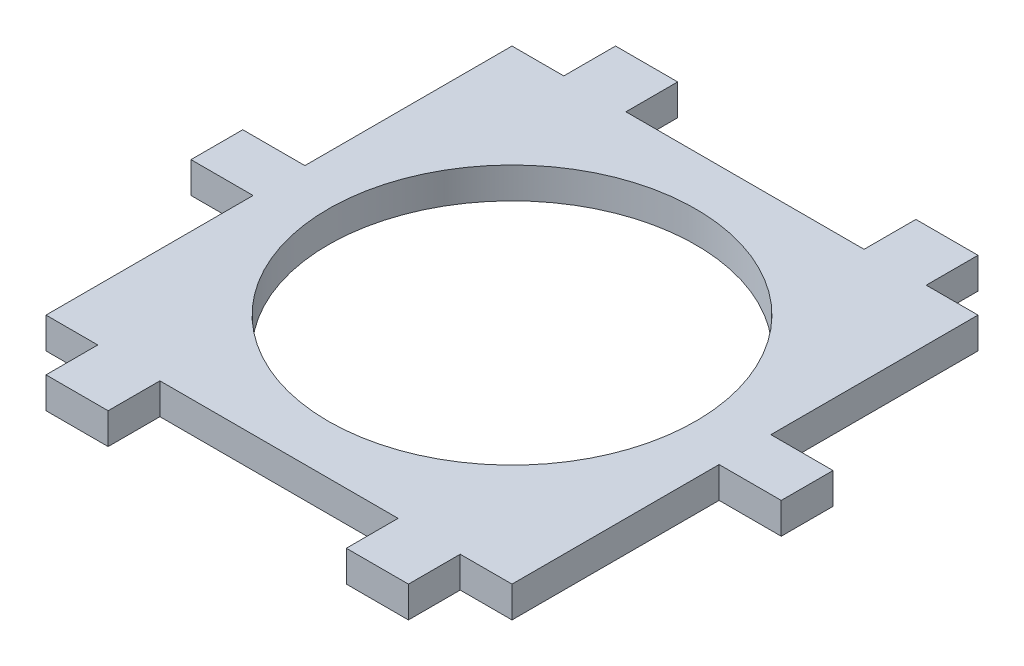
from build123d import *

# Parameters (mm, degrees)
CROQUIS1_R              = 17.75
SALIENTE_EXTRUIR1_DEPTH = 3
CROQUIS1_3_W            = 6
CROQUIS1_3_H            = 5
SALIENTE_EXTRUIR2_DEPTH = 3


with BuildPart() as part:
    # Croquis1 → Saliente-Extruir1 (new body)
    with BuildSketch(Plane(origin=(0, 0, 0), x_dir=(1, 0, 0), z_dir=(0, 1, 0))):
        Polygon((-17.5, 22.5), (-22.5, 22.5), (-22.5, -22.5), (-17.5, -22.5), (-17.5, -27.5), (-11.5, -27.5), (-11.5, -22.5), (11.5, -22.5), (11.5, -27.5), (17.5, -27.5), (17.5, -22.5), (22.5, -22.5), (22.5, 22.5), (17.5, 22.5), (17.5, 27.5), (11.5, 27.5), (11.5, 22.5), (-11.5, 22.5), (-11.5, 27.5), (-17.5, 27.5), align=None)
        Circle(CROQUIS1_R, mode=Mode.SUBTRACT)
    extrude(amount=SALIENTE_EXTRUIR1_DEPTH)

    # Croquis1_3 → Saliente-Extruir2 (add)
    with BuildSketch(Plane(origin=(0, 0, 0), x_dir=(1, 0, 0), z_dir=(0, 1, 0))):
        with Locations((-25.5, 0)):
            Rectangle(CROQUIS1_3_W, CROQUIS1_3_H)
        with Locations((25.5, 0)):
            Rectangle(CROQUIS1_3_W, CROQUIS1_3_H)
    extrude(amount=SALIENTE_EXTRUIR2_DEPTH)


solid = part.part
